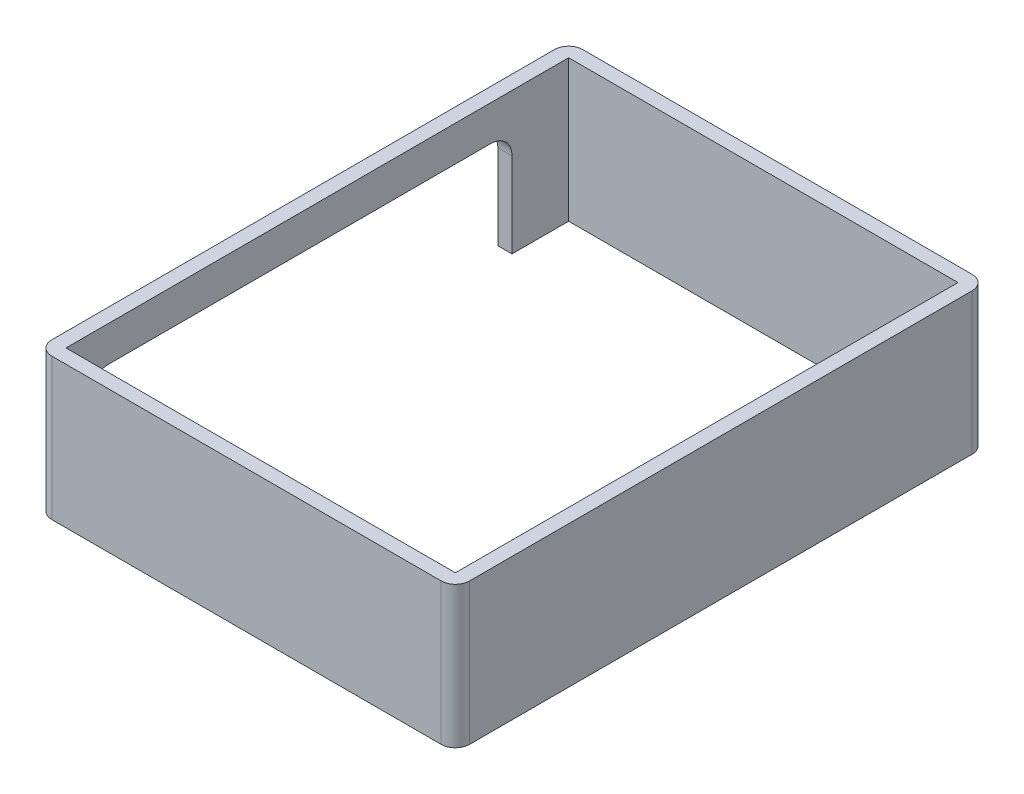
from build123d import *

# Parameters (mm, degrees)
SKETCH1_W           = 55
SKETCH1_H           = 71
BOSS_EXTRUDE1_DEPTH = 20
CUT_EXTRUDE1_DEPTH  = 20


with BuildPart() as part:
    # Sketch1 → Boss-Extrude1 (new body)
    with BuildSketch(Plane(origin=(0, 0, 0), x_dir=(1, 0, 0), z_dir=(0, 1, 0))):
        with BuildLine():
            Line((29.5, -35.5), (29.5, 35.5))
            ThreePointArc((29.5, 35.5), (28.914213562, 36.914213562), (27.5, 37.5))
            Line((27.5, 37.5), (-27.5, 37.5))
            ThreePointArc((-27.5, 37.5), (-28.914213562, 36.914213562), (-29.5, 35.5))
            Line((-29.5, 35.5), (-29.5, -35.5))
            ThreePointArc((-29.5, -35.5), (-28.914213562, -36.914213562), (-27.5, -37.5))
            Line((-27.5, -37.5), (27.5, -37.5))
            ThreePointArc((27.5, -37.5), (28.914213562, -36.914213562), (29.5, -35.5))
        make_face()
        Rectangle(SKETCH1_W, SKETCH1_H, mode=Mode.SUBTRACT)
    extrude(amount=BOSS_EXTRUDE1_DEPTH)

    # Sketch2 → Cut-Extrude1 (cut)
    with BuildSketch(Plane.ZY.offset(29.5)):
        with BuildLine():
            Line((-24.5, 15), (29.5, 15))
            ThreePointArc((29.5, 15), (31.621320344, 14.121320344), (32.5, 12))
            Line((32.5, 12), (32.5, -3))
            Line((32.5, -3), (-27.5, -3))
            Line((-27.5, -3), (-27.5, 12))
            ThreePointArc((-27.5, 12), (-26.621320344, 14.121320344), (-24.5, 15))
        make_face()
    extrude(amount=-CUT_EXTRUDE1_DEPTH, mode=Mode.SUBTRACT)


solid = part.part
